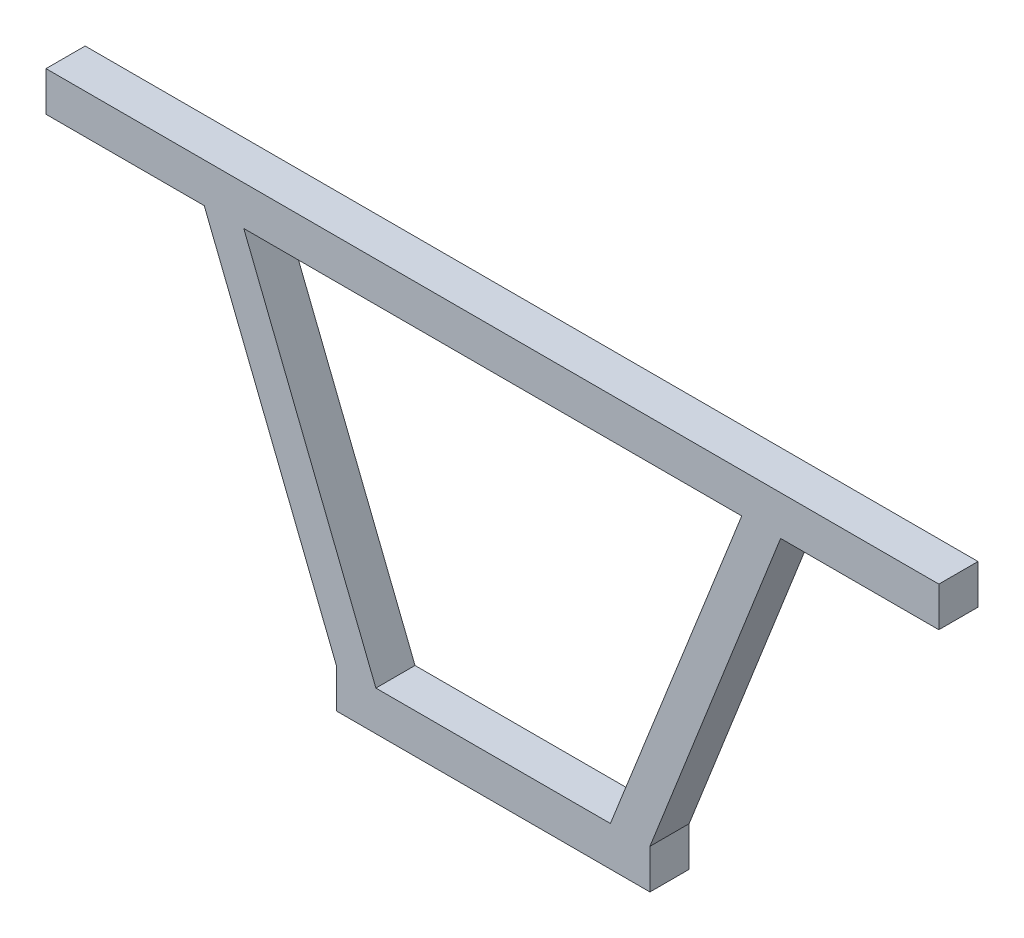
from build123d import *

# Parameters (mm, degrees)
SKETCH1_W      = 228.04397219
SKETCH1_H      = 10.103213958
EXTRUDE1_DEPTH = 10
EXTRUDE2_DEPTH = 10
EXTRUDE3_DEPTH = 10


with BuildPart() as part:
    # Sketch1 → Extrude1 (new body)
    with BuildSketch(Plane.XY):
        with Locations((0, 48.080473567)):
            Rectangle(SKETCH1_W, SKETCH1_H)
    extrude(amount=EXTRUDE1_DEPTH)



with BuildPart() as body_2:
    # Sketch1_3 → Extrude2 (new body)
    with BuildSketch(Plane.XY):
        Polygon((40.232441296, -51.869178801), (40.232441296, -41.765964843), (30.129227338, -41.765964843), (-29.768398268, -41.765964843), (-39.871612226, -41.765964843), (-39.871612226, -51.869178801), align=None)
    extrude(amount=EXTRUDE2_DEPTH)


with BuildPart() as part_1:
    add(part.part)

    add(body_2.part)  # Extrude3 merges body 2
    # Sketch1_4 → Extrude3 (add)
    with BuildSketch(Plane.XY):
        Polygon((40.232441296, -41.765964843), (73.609130264, 43.028866588), (63.686330841, 43.028866588), (30.129227338, -41.765964843), align=None)
        Polygon((-29.768398268, -41.765964843), (-63.505916306, 43.028866588), (-73.609130264, 43.028866588), (-39.871612226, -41.765964843), align=None)
    extrude(amount=EXTRUDE3_DEPTH)


solid = part_1.part
